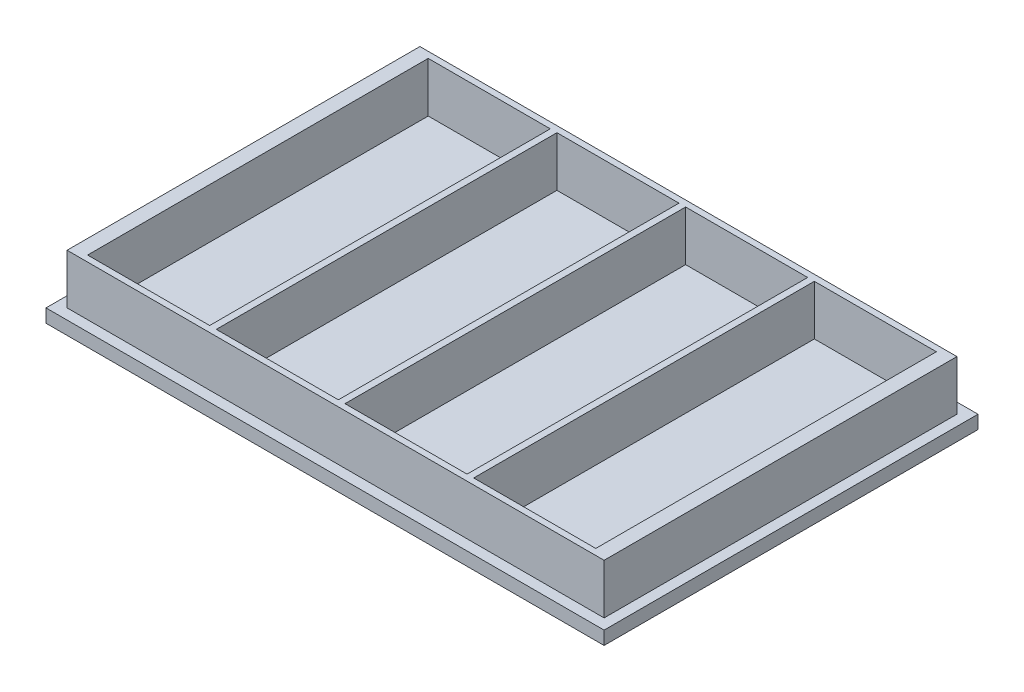
from build123d import *

# Parameters (mm, degrees)
SKETCH1_W           = 127.762
SKETCH1_H           = 85.598
SKETCH1_W_2         = 122.936
SKETCH1_H_2         = 80.772
BOSS_EXTRUDE1_DEPTH = 3.048
SKETCH2_W           = 122.936
SKETCH2_H           = 80.772
BOSS_EXTRUDE2_DEPTH = 2.413
SKETCH3_W           = 122.936
SKETCH3_H           = 80.772
SKETCH3_W_2         = 116.332
SKETCH3_H_2         = 77.978
SKETCH3_W_3         = 1.524
BOSS_EXTRUDE3_DEPTH = 11.43


with BuildPart() as part:
    # Sketch1 → Boss-Extrude1 (new body)
    with BuildSketch(Plane(origin=(0, 0, 0), x_dir=(1, 0, 0), z_dir=(0, 1, 0))):
        with Locations((63.881, -42.799)):
            Rectangle(SKETCH1_W, SKETCH1_H)
        with Locations((63.881, -42.799)):
            Rectangle(SKETCH1_W_2, SKETCH1_H_2, mode=Mode.SUBTRACT)
    extrude(amount=BOSS_EXTRUDE1_DEPTH)

    # Sketch2 → Boss-Extrude2 (add)
    with BuildSketch(Plane(origin=(0, 3.048, 0), x_dir=(1, 0, 0), z_dir=(0, 1, 0))):
        with Locations((63.881, -42.799)):
            Rectangle(SKETCH2_W, SKETCH2_H)
    extrude(amount=-BOSS_EXTRUDE2_DEPTH)

    # Sketch3 → Boss-Extrude3 (add)
    with BuildSketch(Plane(origin=(0, 3.048, 0), x_dir=(1, 0, 0), z_dir=(0, 1, 0))):
        with Locations((63.881, -42.799)):
            Rectangle(SKETCH3_W, SKETCH3_H)
        with Locations((63.881, -42.799)):
            Rectangle(SKETCH3_W_2, SKETCH3_H_2, mode=Mode.SUBTRACT)
        with Locations((34.417, -42.799)):
            Rectangle(SKETCH3_W_3, SKETCH3_H_2)
        with Locations((63.881, -42.799)):
            Rectangle(SKETCH3_W_3, SKETCH3_H_2)
        with Locations((93.345, -42.799)):
            Rectangle(SKETCH3_W_3, SKETCH3_H_2)
    extrude(amount=BOSS_EXTRUDE3_DEPTH)


solid = part.part
